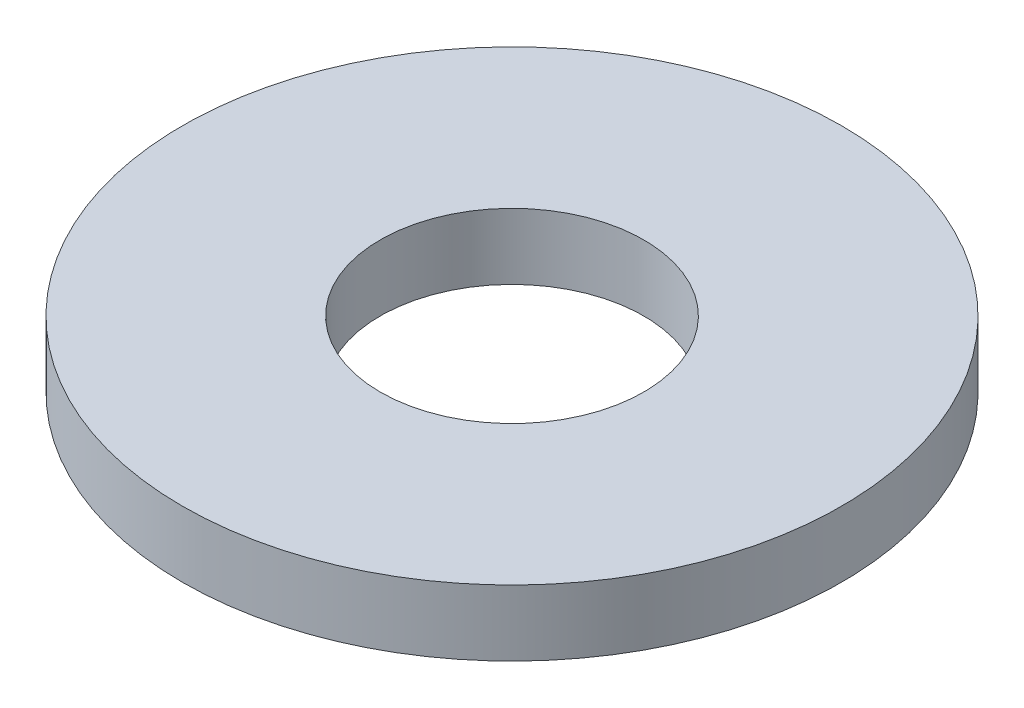
from build123d import *

# Parameters (mm, degrees)
SKETCH_1_R      = 2.5
SKETCH_1_R_2    = 1
EXTRUDE_1_DEPTH = 0.5


with BuildPart() as part:
    # 草图1 → 凸台-拉伸1 (new body)
    with BuildSketch(Plane(origin=(0, 0, 0), x_dir=(1, 0, 0), z_dir=(0, 1, 0))):
        Circle(SKETCH_1_R)
        Circle(SKETCH_1_R_2, mode=Mode.SUBTRACT)
    extrude(amount=EXTRUDE_1_DEPTH)


solid = part.part
